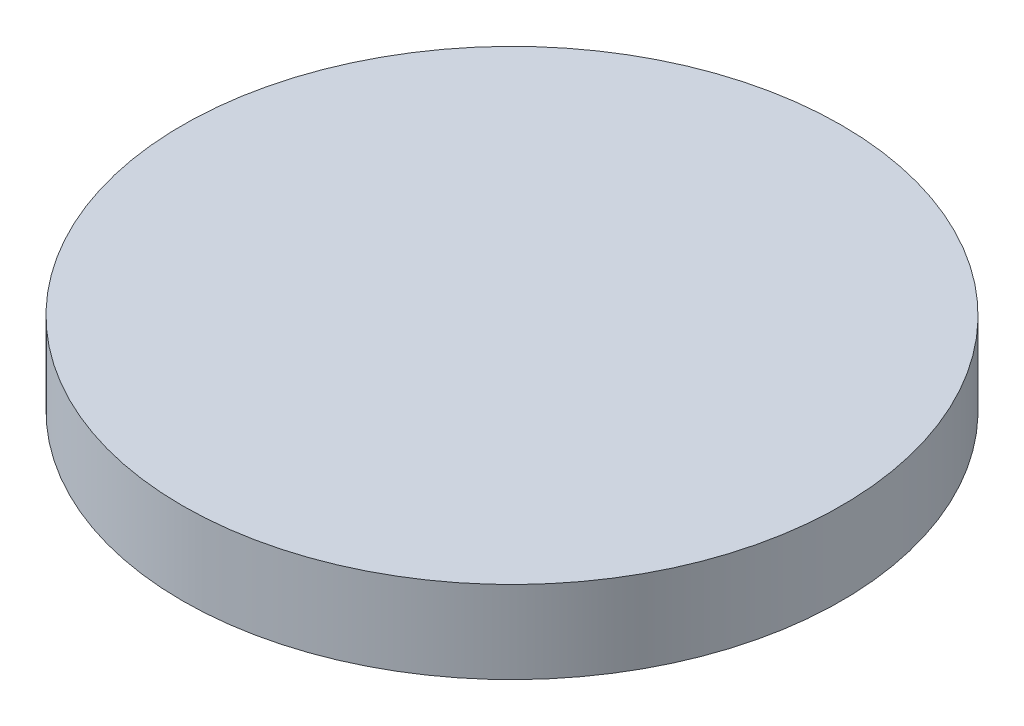
from build123d import *

# Parameters (mm, degrees)
X_Y_SERVO_MOUNT_SKETCH_R = 12.7
X_Y_SERVO_MOUNT_DEPTH    = 3.175


with BuildPart() as part:
    # X-Y Servo Mount Sketch → X-Y Servo Mount (new body)
    with BuildSketch(Plane(origin=(0, 0, 0), x_dir=(1, 0, 0), z_dir=(0, 1, 0))):
        Circle(X_Y_SERVO_MOUNT_SKETCH_R)
    extrude(amount=X_Y_SERVO_MOUNT_DEPTH)


solid = part.part
